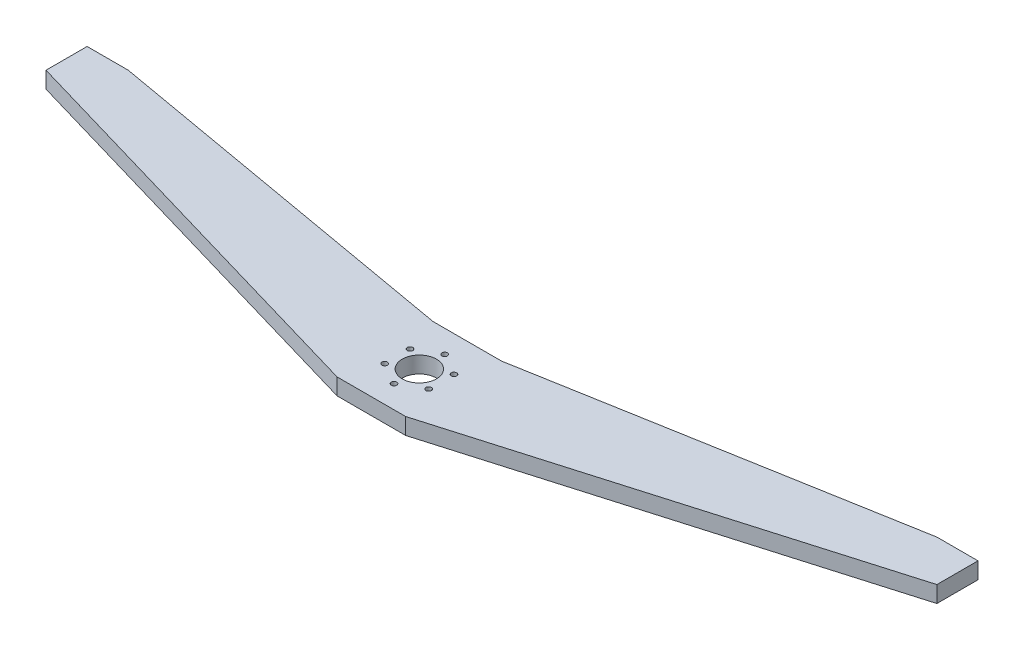
from build123d import *

# Parameters (mm, degrees)
BOSS_EXTRUDE1_DEPTH = 12
SKETCH4_R           = 12.5
SKETCH4_R_2         = 2
CUT_EXTRUDE1_DEPTH  = 20


with BuildPart() as part:
    # Sketch2 → Boss-Extrude1 (new body)
    with BuildSketch(Plane(origin=(0, 0, 0), x_dir=(1, 0, 0), z_dir=(0, 1, 0))):
        Polygon((-318.206861599, 87.608284791), (-18.206861599, 0), (31.793138401, 0), (331.793138401, 87.608284791), (331.793138401, 117.608284791), (301.793138401, 117.608284791), (31.793138401, 70), (-18.206861599, 70), (-288.206861599, 117.608284791), (-318.206861599, 117.608284791), align=None)
    extrude(amount=BOSS_EXTRUDE1_DEPTH)

    # Sketch4 → Cut-Extrude1 (cut)
    with BuildSketch(Plane(origin=(0, 12, 0), x_dir=(1, 0, 0), z_dir=(0, 1, 0))):
        with Locations((6.793138401, 35)):
            Circle(SKETCH4_R)
        with Locations((6.793138401, 53.5)):
            Circle(SKETCH4_R_2)
        with Locations((22.814608371, 44.25)):
            Circle(SKETCH4_R_2)
        with Locations((22.814608371, 25.75)):
            Circle(SKETCH4_R_2)
        with Locations((6.793138401, 16.5)):
            Circle(SKETCH4_R_2)
        with Locations((-9.228331569, 25.75)):
            Circle(SKETCH4_R_2)
        with Locations((-9.228331569, 44.25)):
            Circle(SKETCH4_R_2)
    extrude(amount=-CUT_EXTRUDE1_DEPTH, mode=Mode.SUBTRACT)


solid = part.part
